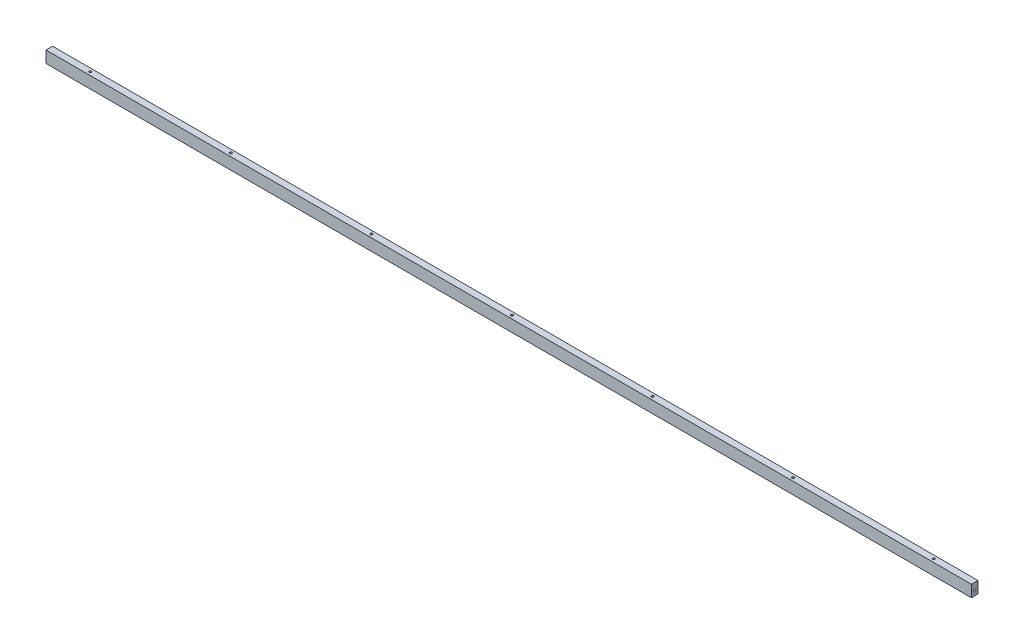
from build123d import *

# Parameters (mm, degrees)
SKETCH_1_W             = 1975
SKETCH_1_H             = 25
EXTRUDE_1_DEPTH        = 7
HOLE_WIZARD_M6_1_D     = 5
HOLE_WIZARD_M6_1_DEPTH = 15
HOLE_WIZARD_M6_1_TIP   = 1.502151548


with BuildPart() as part:
    # 草图1 → 凸台-拉伸1 (new body, symmetric)
    with BuildSketch(Plane.XY):
        Rectangle(SKETCH_1_W, SKETCH_1_H)
    extrude(amount=EXTRUDE_1_DEPTH, both=True)

    # M6 螺纹孔1
    with Locations(Plane(origin=(-900, 12.5, 0), x_dir=(0, 0, 1), z_dir=(0, 1, 0))):
        with Locations((0, 0), (0, 300), (0, 600), (0, 1800), (0, 1500), (0, 1200), (0, 900)):
            Hole(HOLE_WIZARD_M6_1_D / 2, depth=HOLE_WIZARD_M6_1_DEPTH)
            with Locations((0, 0, -(HOLE_WIZARD_M6_1_DEPTH + HOLE_WIZARD_M6_1_TIP / 2))):  # 118° drill point
                Cone(0, HOLE_WIZARD_M6_1_D / 2, HOLE_WIZARD_M6_1_TIP, mode=Mode.SUBTRACT)

    # 草图6 → M6 螺纹孔2 (revolve, cut)
    with BuildSketch(Plane(origin=(987.5, -2.5, 0), x_dir=(0, 0, -1), z_dir=(0, 1, 0))):
        Polygon((0, 0), (0, 16.502151548), (2.5, 15), (2.5, 0), align=None)
    hole_wizard_m6_2 = revolve(axis=Axis((993.85, -2.5, 0), (-1, 0, 0)), mode=Mode.SUBTRACT)

    # 镜向1: M6 螺纹孔2 across plane
    add(hole_wizard_m6_2.mirror(Plane(origin=(0, 0, 0), x_dir=(0, 0, 1), z_dir=(1, 0, 0))), mode=Mode.SUBTRACT)

    # 镜向2 copy 1 sketch → 镜向2 copy 1 (revolve, cut)
    with BuildSketch(Plane(origin=(987.5, -2.5, 0), x_dir=(0, 0, -1), z_dir=(0, 1, 0))):
        Polygon((0, 0), (0, 16.502151548), (2.5, 15), (2.5, 0), align=None)
    revolve(axis=Axis((993.85, -2.5, 0), (-1, 0, 0)), mode=Mode.SUBTRACT)

    # 镜向2 copy 2 sketch → 镜向2 copy 2 (revolve, cut)
    with BuildSketch(Plane(origin=(-987.5, -2.5, 0), x_dir=(0, 0, -1), z_dir=(0, 1, 0))):
        Polygon((0, 0), (0, -16.502151548), (2.5, -15), (2.5, 0), align=None)
    revolve(axis=Axis((-993.85, -2.5, 0), (-1, 0, 0)), mode=Mode.SUBTRACT)


solid = part.part
